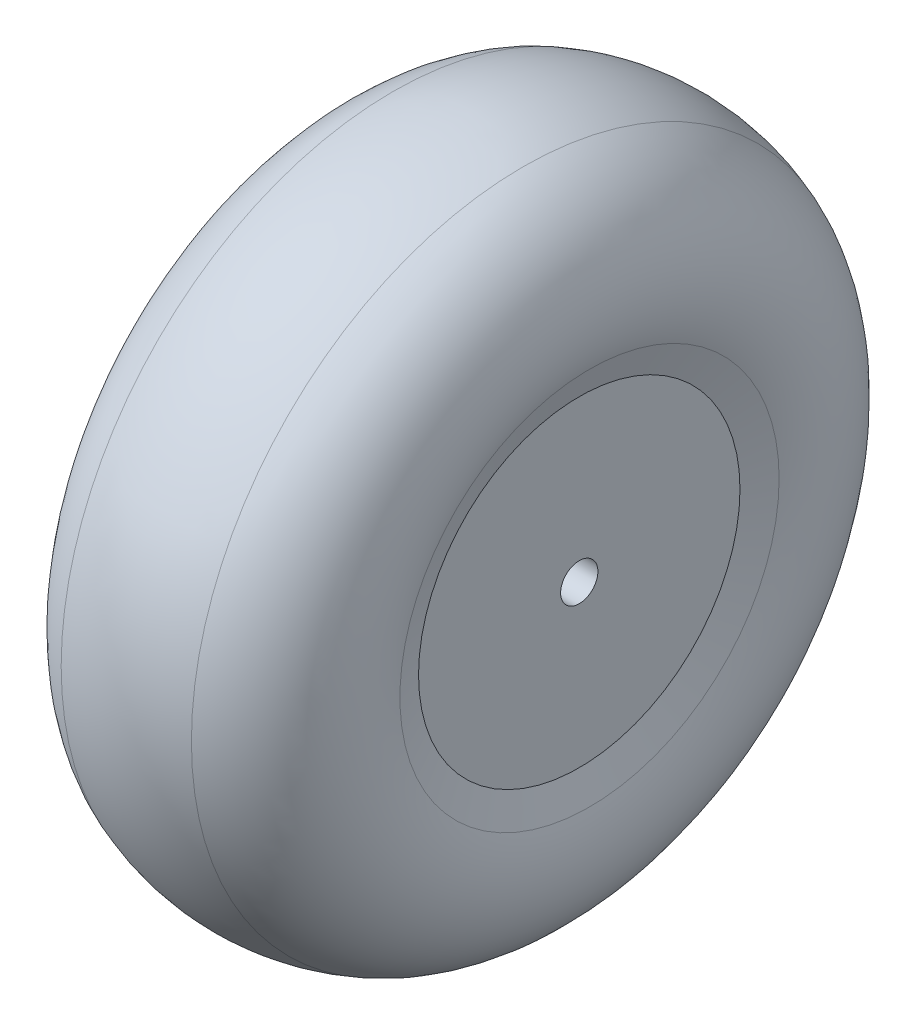
from build123d import *

# Parameters (mm, degrees)
SKETCH1_R               = 17.25
BOSS_EXTRUDE1_DEPTH     = 26
FILLET1_R               = 20
FILLET2_R               = 12
SKETCH3_R               = 2
CUT_EXTRUDE1_DEPTH      = 2.795288953
CUT_EXTRUDE1_DEPTH_BACK = 28.795288953


with BuildPart() as part:
    # Sketch1 → Boss-Extrude1 (new body)
    with BuildSketch(Plane(origin=(0, 0, 0), x_dir=(0, 0, -1), z_dir=(1, 0, 0))):
        Circle(SKETCH1_R)
    extrude(amount=BOSS_EXTRUDE1_DEPTH)

    # Sketch2 → Revolve1 (revolve)
    with BuildSketch(Plane.XY):
        with BuildLine():
            Line((-4.622703996, 30.25), (0, 17.25))
            Line((0, 17.25), (26, 17.25))
            Line((26, 17.25), (30.622703996, 30.25))
            ThreePointArc((30.622703996, 30.25), (22.131370856, 34.751946348), (13, 37.75))
            ThreePointArc((13, 37.75), (3.868629144, 34.751946348), (-4.622703996, 30.25))
        make_face()
    revolve(axis=Axis((0, 0, 0), (1, 0, 0)))

    # Fillet1
    fillet1_edges = [part.edges().sort_by_distance(p)[0] for p in [
        (13, -37.75, 0),
    ]]
    fillet(fillet1_edges, radius=FILLET1_R)

    # Fillet2
    fillet2_edges = [part.edges().sort_by_distance(p)[0] for p in [
        (-4.622703996, -30.25, 0),
        (30.622703996, -30.25, 0),
    ]]
    fillet(fillet2_edges, radius=FILLET2_R)

    # Sketch3 → Cut-Extrude1 (cut, two sides)
    with BuildSketch(Plane.ZY) as cut_extrude1_sk:
        Circle(SKETCH3_R)
    extrude(amount=CUT_EXTRUDE1_DEPTH, mode=Mode.SUBTRACT)
    extrude(cut_extrude1_sk.sketch, amount=-CUT_EXTRUDE1_DEPTH_BACK, mode=Mode.SUBTRACT)


solid = part.part
